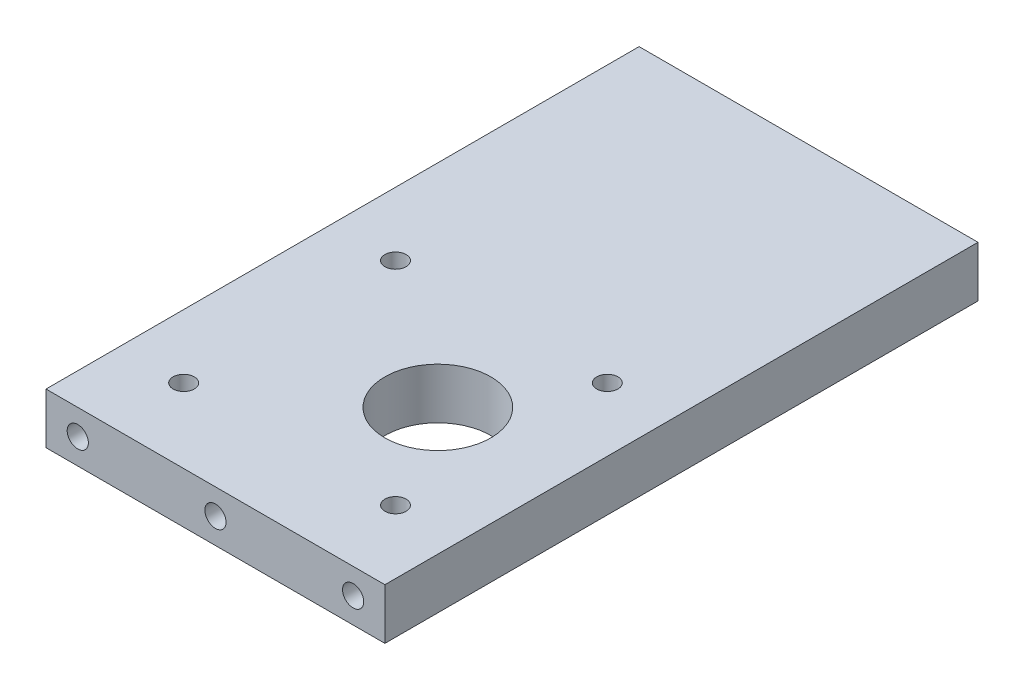
from build123d import *

# Parameters (mm, degrees)
SKETCH1_W                        = 80
SKETCH1_H                        = 140
SKETCH1_R                        = 12.5
BOSS_EXTRUDE1_DEPTH              = 6
TAP_DRILL_FOR_M6_TAP1_D          = 5
TAP_DRILL_FOR_M6_TAP2_AT_2_COUNT = 2
TAP_DRILL_FOR_M6_TAP2_AT_2_PITCH = 32.5
TAP_DRILL_FOR_M6_TAP2_AT_3_COUNT = 2
TAP_DRILL_FOR_M6_TAP2_AT_3_PITCH = 65
TAP_DRILL_FOR_M6_TAP3_D          = 5
TAP_DRILL_FOR_M6_TAP3_DEPTH      = 26
TAP_DRILL_FOR_M6_TAP3_TIP        = 1.502151548


with BuildPart() as part:
    # Sketch1 → Boss-Extrude1 (new body, symmetric)
    with BuildSketch(Plane(origin=(0, 0, 0), x_dir=(1, 0, 0), z_dir=(0, 1, 0))):
        with Locations((0, 70)):
            Rectangle(SKETCH1_W, SKETCH1_H)
        with Locations((10, 42.5)):
            Circle(SKETCH1_R, mode=Mode.SUBTRACT)
    extrude(amount=BOSS_EXTRUDE1_DEPTH, both=True)

    # Tap Drill for M6 Tap1 (through all)
    with Locations(Plane(origin=(0, 6, 0), x_dir=(1, 0, 0), z_dir=(0, 1, 0))):
        with Locations((-25, 67.5), (25, 67.5), (25, 17.5), (-25, 17.5)):
            Hole(TAP_DRILL_FOR_M6_TAP1_D / 2)

    # Sketch9 → Tap Drill for M6 Tap2 (revolve, cut)
    with BuildSketch(Plane(origin=(32.5, 0, 0), x_dir=(0, -1, 0), z_dir=(1, 0, 0))):
        Polygon((0, 0), (0, 21.502151548), (2.5, 20), (2.5, 0), align=None)
    tap_drill_for_m6_tap2 = revolve(axis=Axis((32.5, 0, 6.35), (0, 0, -1)), mode=Mode.SUBTRACT)

    # Tap Drill for M6 Tap2 at 2: Tap Drill for M6 Tap2 ×2
    with Locations(*[(-i * TAP_DRILL_FOR_M6_TAP2_AT_2_PITCH, 0, 0) for i in range(1, TAP_DRILL_FOR_M6_TAP2_AT_2_COUNT)]):
        add(tap_drill_for_m6_tap2, mode=Mode.SUBTRACT)

    # Tap Drill for M6 Tap2 at 3: Tap Drill for M6 Tap2 ×2
    with Locations(*[(-i * TAP_DRILL_FOR_M6_TAP2_AT_3_PITCH, 0, 0) for i in range(1, TAP_DRILL_FOR_M6_TAP2_AT_3_COUNT)]):
        add(tap_drill_for_m6_tap2, mode=Mode.SUBTRACT)

    # Mirror1: Tap Drill for M6 Tap2 across plane
    add(tap_drill_for_m6_tap2.mirror(Plane(origin=(0, 0, -70), x_dir=(1, 0, 0), z_dir=(0, 0, -1))), mode=Mode.SUBTRACT)

    # Mirror1 copy 1 sketch → Mirror1 copy 1 (revolve, cut)
    with BuildSketch(Plane(origin=(0, 0, -140), x_dir=(0, -1, 0), z_dir=(1, 0, 0))):
        Polygon((0, 0), (0, -21.502151548), (2.5, -20), (2.5, 0), align=None)
    revolve(axis=Axis((0, 0, -146.35), (0, 0, -1)), mode=Mode.SUBTRACT)

    # Mirror1 copy 2 sketch → Mirror1 copy 2 (revolve, cut)
    with BuildSketch(Plane(origin=(-32.5, 0, -140), x_dir=(0, -1, 0), z_dir=(1, 0, 0))):
        Polygon((0, 0), (0, -21.502151548), (2.5, -20), (2.5, 0), align=None)
    revolve(axis=Axis((-32.5, 0, -146.35), (0, 0, -1)), mode=Mode.SUBTRACT)

    # Tap Drill for M6 Tap3
    with Locations(Plane.ZY.offset(40)):
        with Locations((-113, 0), (-86, 0), (-56, 0), (-29, 0)):
            Hole(TAP_DRILL_FOR_M6_TAP3_D / 2, depth=TAP_DRILL_FOR_M6_TAP3_DEPTH)
            with Locations((0, 0, -(TAP_DRILL_FOR_M6_TAP3_DEPTH + TAP_DRILL_FOR_M6_TAP3_TIP / 2))):  # 118° drill point
                Cone(0, TAP_DRILL_FOR_M6_TAP3_D / 2, TAP_DRILL_FOR_M6_TAP3_TIP, mode=Mode.SUBTRACT)


solid = part.part
